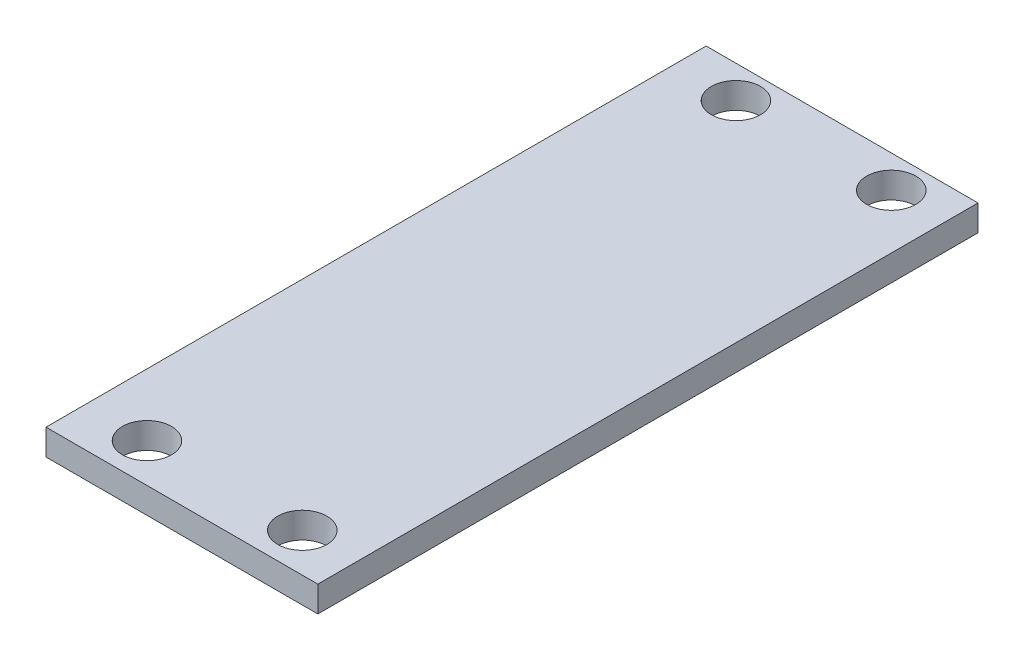
from build123d import *

# Parameters (mm, degrees)
SKETCH1_W           = 21
SKETCH1_H           = 51
SKETCH1_R           = 1.9
BOSS_EXTRUDE1_DEPTH = 2


with BuildPart() as part:
    # Sketch1 → Boss-Extrude1 (new body)
    with BuildSketch(Plane(origin=(0, 0, 0), x_dir=(1, 0, 0), z_dir=(0, 1, 0))):
        with Locations((-3.945020747, -12.481327801)):
            Rectangle(SKETCH1_W, SKETCH1_H)
        with Locations((-9.645020747, 10.518672199)):
            Circle(SKETCH1_R, mode=Mode.SUBTRACT)
        with Locations((2.354979253, 10.518672199)):
            Circle(SKETCH1_R, mode=Mode.SUBTRACT)
        with Locations((2.354979253, -34.981327801)):
            Circle(SKETCH1_R, mode=Mode.SUBTRACT)
        with Locations((-9.645020747, -34.981327801)):
            Circle(SKETCH1_R, mode=Mode.SUBTRACT)
    extrude(amount=BOSS_EXTRUDE1_DEPTH)


solid = part.part
